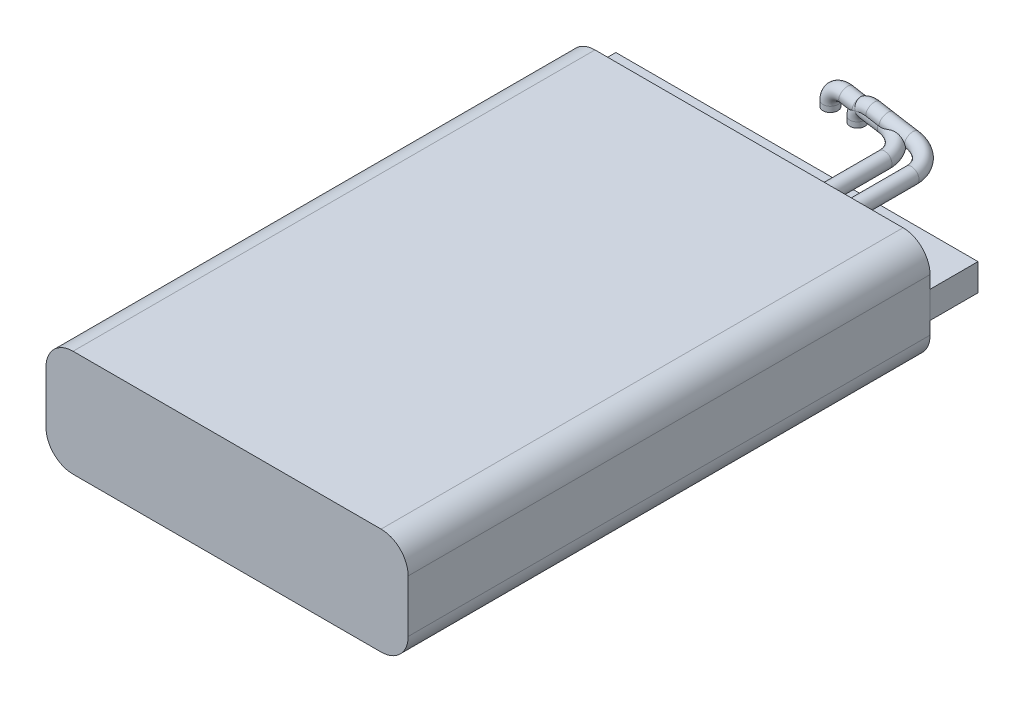
from build123d import *

# Parameters (mm, degrees)
SKETCH1_W           = 34
SKETCH1_H           = 49
BOSS_EXTRUDE1_DEPTH = 5
FILLET1_R           = 2.54
BOSS_EXTRUDE2_START = -53.5
SKETCH2_W           = 34
SKETCH2_H           = 2.54
BOSS_EXTRUDE2_DEPTH = 4.5
SWEEP2_PROFILE_R    = 0.6985


with BuildPart() as part:
    # Sketch1 → Boss-Extrude1 (new body, symmetric)
    with BuildSketch(Plane(origin=(0, 0, 0), x_dir=(1, 0, 0), z_dir=(0, 1, 0))):
        Rectangle(SKETCH1_W, SKETCH1_H)
    extrude(amount=BOSS_EXTRUDE1_DEPTH, both=True)

    # Fillet1
    fillet1_edges = [part.edges().sort_by_distance(p)[0] for p in [
        (17, 5, 0),
        (-17, 5, 0),
        (17, -5, 0),
        (-17, -5, 0),
    ]]
    fillet(fillet1_edges, radius=FILLET1_R)


with BuildPart() as body_2:
    # Sketch2 → Boss-Extrude2 (new body)
    with BuildSketch(Plane.XY.offset(24.5).offset(BOSS_EXTRUDE2_START)):
        Rectangle(SKETCH2_W, SKETCH2_H)
    extrude(amount=BOSS_EXTRUDE2_DEPTH)


with BuildPart() as body_3:
    # Sweep2: sweep along a curve in space
    with BuildLine() as sweep2_path:
        Line((-2.54, 1.27, -34.682), (-2.54, 1.778, -34.682))
        ThreePointArc((-2.54, 1.778, -34.682), (-2.086208877, 2.750986674, -34.682), (-1.049129026, 3.028646238, -34.682))
        Line((0.201517212, 2.807775264, -34.682), (-1.049129026, 3.028646238, -34.682))
        ThreePointArc((0.201517212, 2.807775264, -34.682), (1.38433901, 2.605764371, -34.682), (2.569367138, 2.417126777, -34.682))
        ThreePointArc((2.569367138, 2.417126777, -34.682), (4.34465266, 2.144801021, -33.938051224), (5.08, 2.032, -32.142))
        Line((5.08, 2.032, -32.142), (5.08, 2.032, -24.522))
    # Sweep2 profile (on start of the path) → Sweep2 (sweep)
    with BuildSketch(Plane(origin=(-2.54, 1.27, -34.682), x_dir=(0, 0, 1), z_dir=(0, 1, 0))):
        Circle(SWEEP2_PROFILE_R)
    sweep(path=sweep2_path.line)


with BuildPart() as body_4:
    # Body-Move/Copy1: copy of body 3
    add(body_3.part.moved(Location((2.54, 0, 0))))


solid = Compound([part.part, body_2.part, body_3.part, body_4.part])
